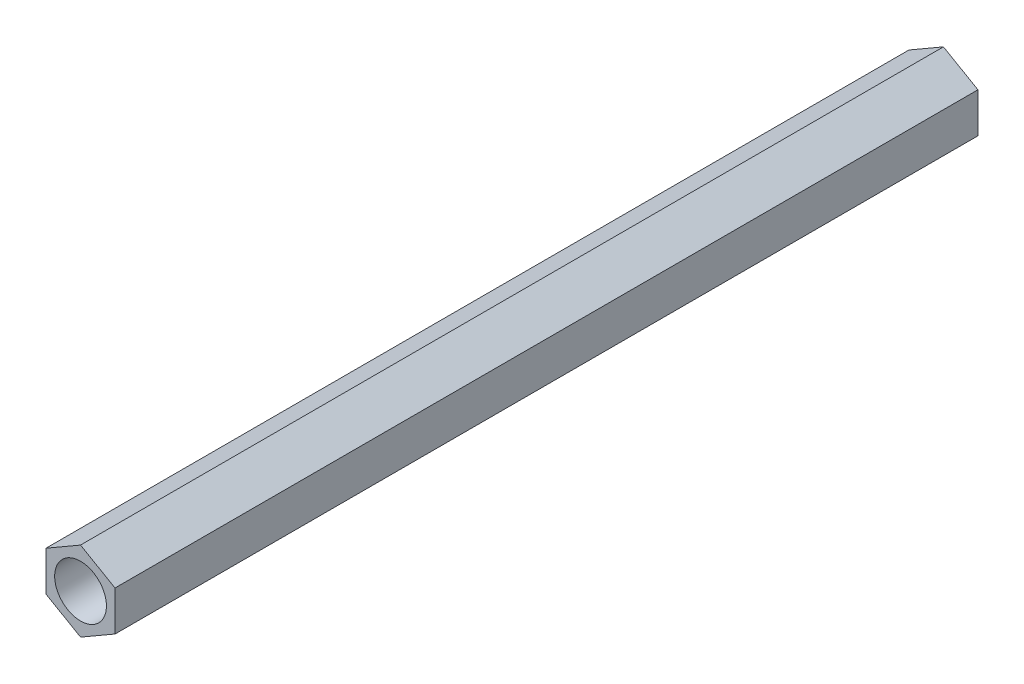
from build123d import *

# Parameters (mm, degrees)
ESQUISSE1_R        = 1.5
BOSS_EXTRU_1_DEPTH = 50


with BuildPart() as part:
    # Esquisse1 → Boss.-Extru.1 (new body)
    with BuildSketch(Plane.XY):
        Polygon((2.001187614, -1.152641083), (1.998810266, 1.15675877), (-0.002377348, 2.309399853), (-2.001187614, 1.152641083), (-1.998810266, -1.15675877), (0.002377348, -2.309399853), align=None)
        Circle(ESQUISSE1_R, mode=Mode.SUBTRACT)
    extrude(amount=BOSS_EXTRU_1_DEPTH)


solid = part.part
